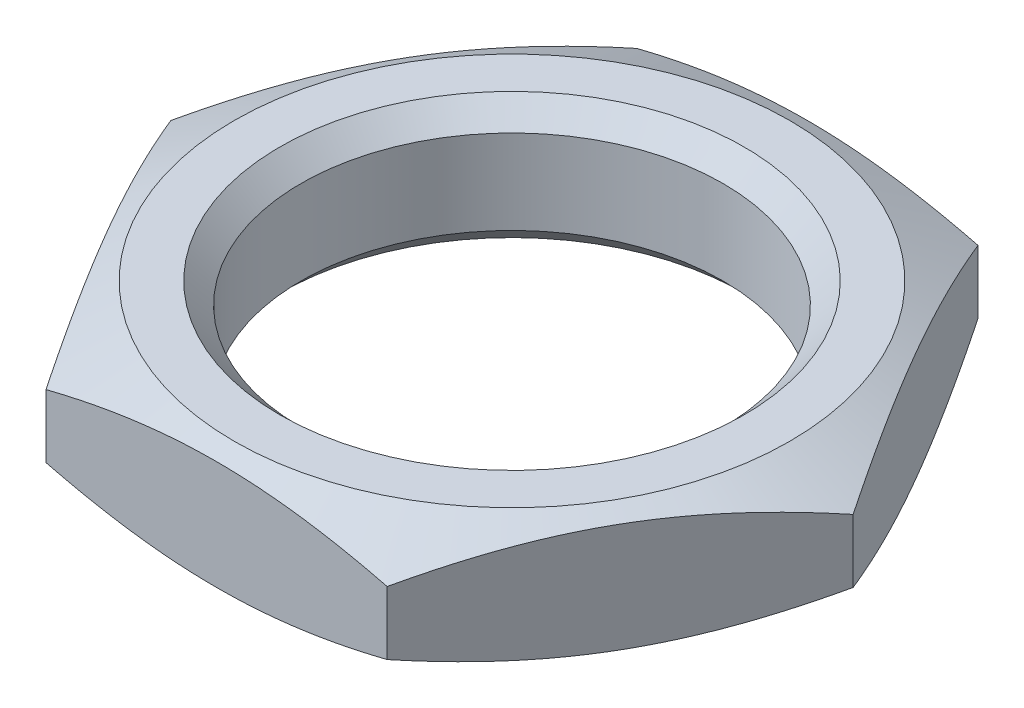
from build123d import *

# Parameters (mm, degrees)
SKETCH1_R           = 5
BOSS_EXTRUDE1_DEPTH = 1.5
CHAMFER1_SIZE       = 0.5


with BuildPart() as part:
    # Sketch1 → Boss-Extrude1 (new body, symmetric)
    with BuildSketch(Plane(origin=(0, 0, 0), x_dir=(1, 0, 0), z_dir=(0, 1, 0))):
        Polygon((8.082903769, 0), (4.041451884, 7), (-4.041451884, 7), (-8.082903769, 0), (-4.041451884, -7), (4.041451884, -7), align=None)
        Circle(SKETCH1_R, mode=Mode.SUBTRACT)
    extrude(amount=BOSS_EXTRUDE1_DEPTH, both=True)

    # Sketch2 → Cut-Revolve1 (revolve, cut)
    with BuildSketch(Plane.XY):
        Polygon((-8.082903769, 1.5), (-6.582903769, 1.5), (-8.082903769, 0.75), align=None)
        Polygon((-8.082903769, -0.75), (-8.082903769, -1.5), (-6.582903769, -1.5), align=None)
    revolve(axis=Axis((0, -1000, 0), (0, 1, 0)), mode=Mode.SUBTRACT)

    # Chamfer1
    chamfer1_edges = [part.edges().sort_by_distance(p)[0] for p in [
        (-5, -1.5, 0),
        (-5, 1.5, 0),
    ]]
    chamfer(chamfer1_edges, length=CHAMFER1_SIZE)


solid = part.part
